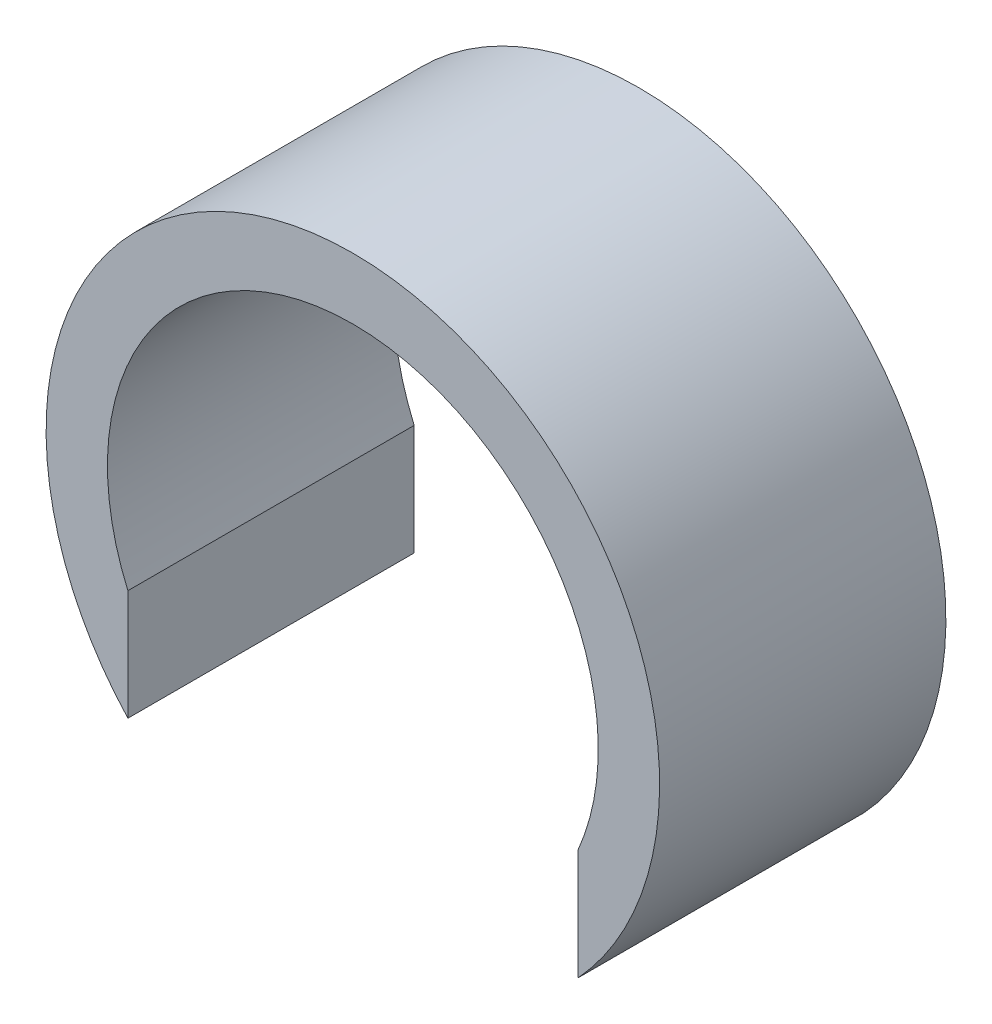
from build123d import *

# Parameters (mm, degrees)
EXTRUDE_1_DEPTH = 7


with BuildPart() as part:
    # ｽｹｯﾁ1 → ﾎﾞｽ - 押し出し1 (new body)
    with BuildSketch(Plane.XY):
        with BuildLine():
            Line((5.5, -5.099019514), (5.5, -2.397915762))
            ThreePointArc((5.5, -2.397915762), (0, 6), (-5.5, -2.397915762))
            Line((-5.5, -2.397915762), (-5.5, -5.099019514))
            ThreePointArc((-5.5, -5.099019514), (0, 7.5), (5.5, -5.099019514))
        make_face()
    extrude(amount=EXTRUDE_1_DEPTH)


solid = part.part
